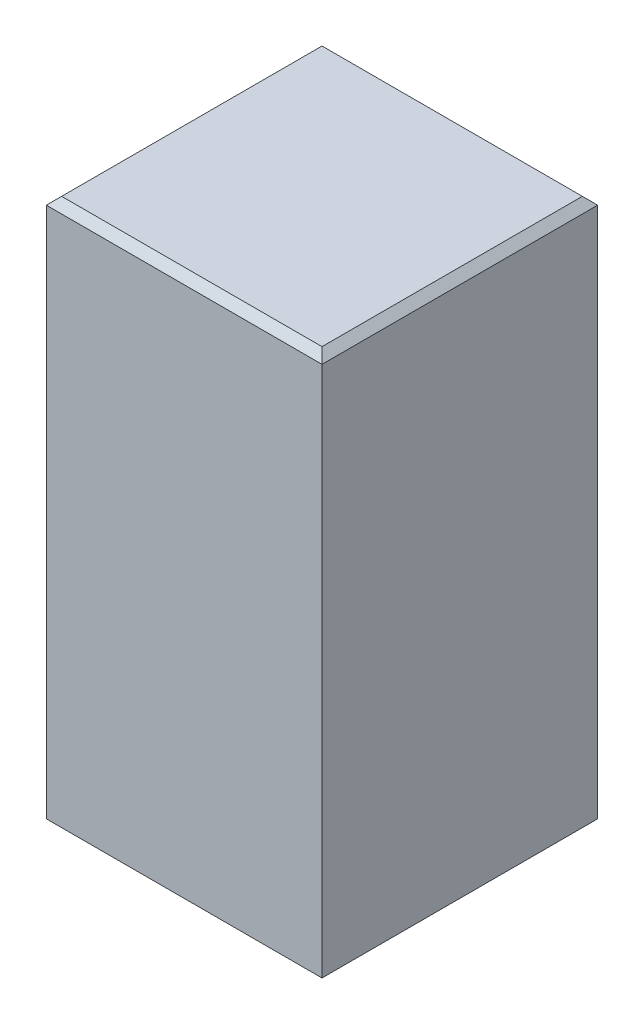
from build123d import *

# Parameters (mm, degrees)
SKETCH1_W           = 18
SKETCH1_H           = 18
SKETCH1_W_2         = 16.4
SKETCH1_H_2         = 16.4
BOSS_EXTRUDE1_DEPTH = 34
SKETCH2_W           = 18
SKETCH2_H           = 18
BOSS_EXTRUDE2_DEPTH = 1.2
CHAMFER1_SIZE       = 0.5


with BuildPart() as part:
    # Sketch1 → Boss-Extrude1 (new body)
    with BuildSketch(Plane(origin=(0, 0, 0), x_dir=(1, 0, 0), z_dir=(0, 1, 0))):
        Rectangle(SKETCH1_W, SKETCH1_H)
        Rectangle(SKETCH1_W_2, SKETCH1_H_2, mode=Mode.SUBTRACT)
    extrude(amount=BOSS_EXTRUDE1_DEPTH)

    # Sketch2 → Boss-Extrude2 (add)
    with BuildSketch(Plane(origin=(0, 34, 0), x_dir=(1, 0, 0), z_dir=(0, 1, 0))):
        Rectangle(SKETCH2_W, SKETCH2_H)
    extrude(amount=BOSS_EXTRUDE2_DEPTH)

    # Chamfer1
    chamfer1_edges = [part.edges().sort_by_distance(p)[0] for p in [
        (-9, 35.2, 0),
        (0, 35.2, 9),
        (9, 35.2, 0),
        (0, 35.2, -9),
    ]]
    chamfer(chamfer1_edges, length=CHAMFER1_SIZE)


solid = part.part
